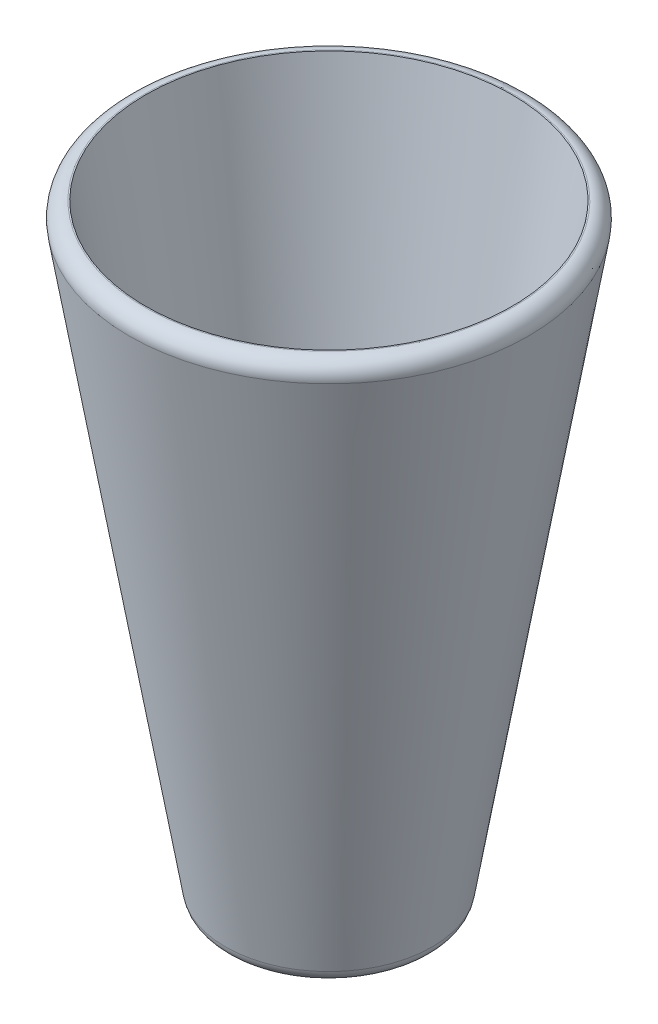
from build123d import *

# Parameters (mm, degrees)
FILLET1_R = 30


with BuildPart() as part:
    # Sketch1 → Revolve1 (revolve)
    with BuildSketch(Plane.XY):
        Polygon((0, -350.590646864), (0, -380.841690926), (200, -380.841690926), (400, 819.158309074), (362.065606136, 819.158309074), (167.107446813, -350.590646864), align=None)
    revolve(axis=Axis((0, -350.590646864, 0), (0, -1, 0)))

    # Fillet1
    fillet1_edges = [part.edges().sort_by_distance(p)[0] for p in [
        (-200, -380.841690926, 0),
        (-400, 819.158309074, 0),
    ]]
    fillet(fillet1_edges, radius=FILLET1_R)


solid = part.part
